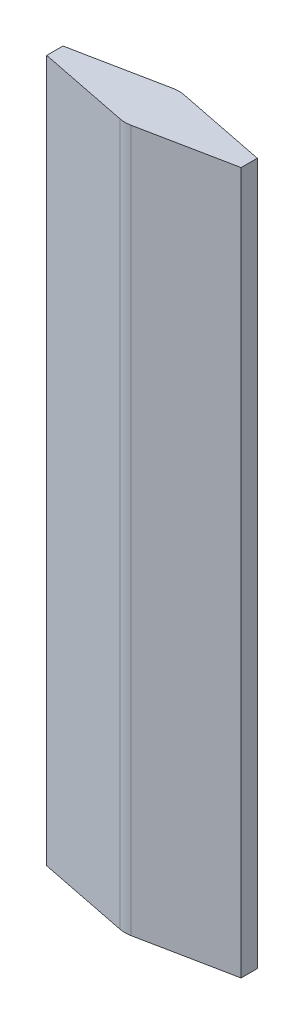
from build123d import *

# Parameters (mm, degrees)
EXTRUDE_1_DEPTH = 650


with BuildPart() as part:
    # 草图5 → 凸台-拉伸1 (new body, symmetric)
    with BuildSketch(Plane(origin=(0, 0, 0), x_dir=(1, 0, 0), z_dir=(0, 1, 0))):
        with BuildLine():
            Line((180, 0), (180, -15.011157988))
            Line((180, -15.011157988), (9.8, -49.030194778))
            ThreePointArc((9.8, -49.030194778), (0, -50), (-9.8, -49.030194778))
            Line((-9.8, -49.030194778), (-180, -15.011157988))
            Line((-180, -15.011157988), (-180, 0))
            Line((-180, 0), (-180, 15.011157988))
            Line((-180, 15.011157988), (-9.799999967, 49.030194785))
            ThreePointArc((-9.799999967, 49.030194785), (1.7e-08, 50), (9.8, 49.030194778))
            Line((9.8, 49.030194778), (180, 15.011157988))
            Line((180, 15.011157988), (180, 0))
        make_face()
    extrude(amount=EXTRUDE_1_DEPTH, both=True)


solid = part.part
